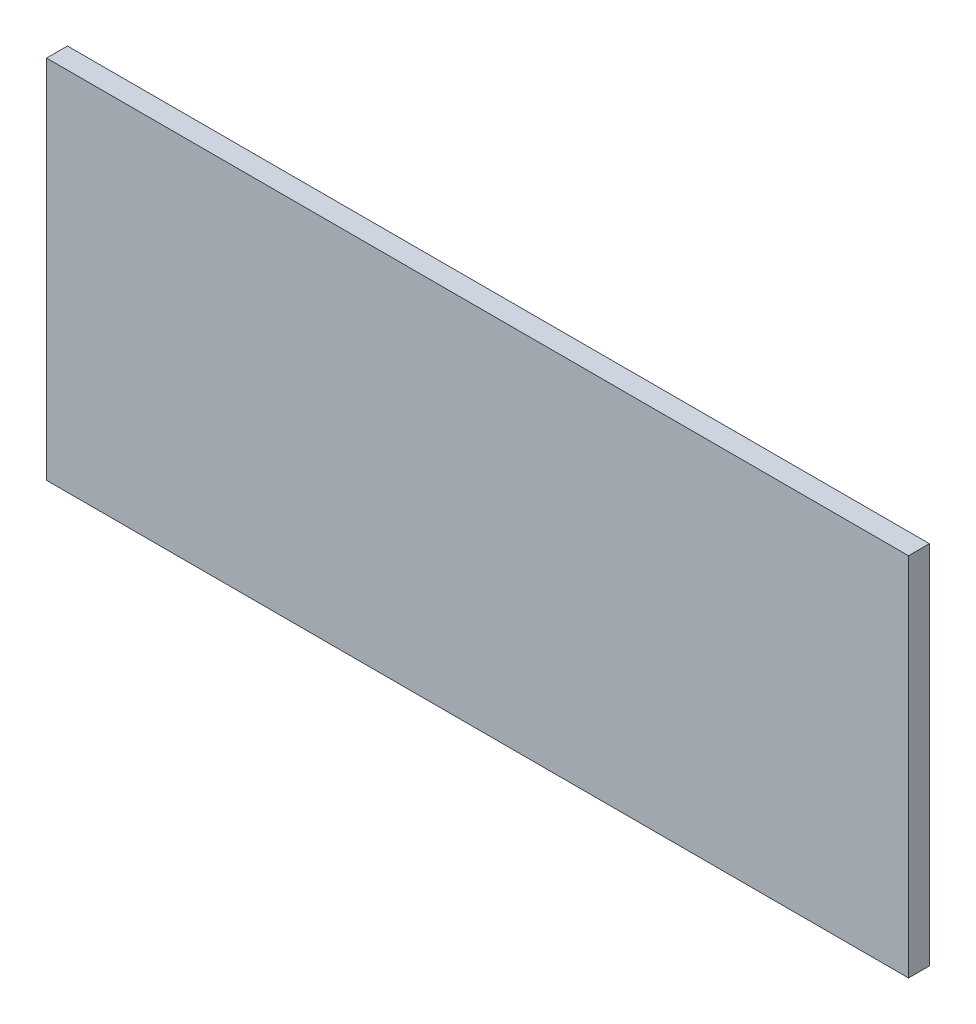
from build123d import *

# Parameters (mm, degrees)
SKETCH1_W           = 165
SKETCH1_H           = 70
BOSS_EXTRUDE1_DEPTH = 4


with BuildPart() as part:
    # Sketch1 → Boss-Extrude1 (new body)
    with BuildSketch(Plane.XY):
        Rectangle(SKETCH1_W, SKETCH1_H)
    extrude(amount=BOSS_EXTRUDE1_DEPTH)


solid = part.part
